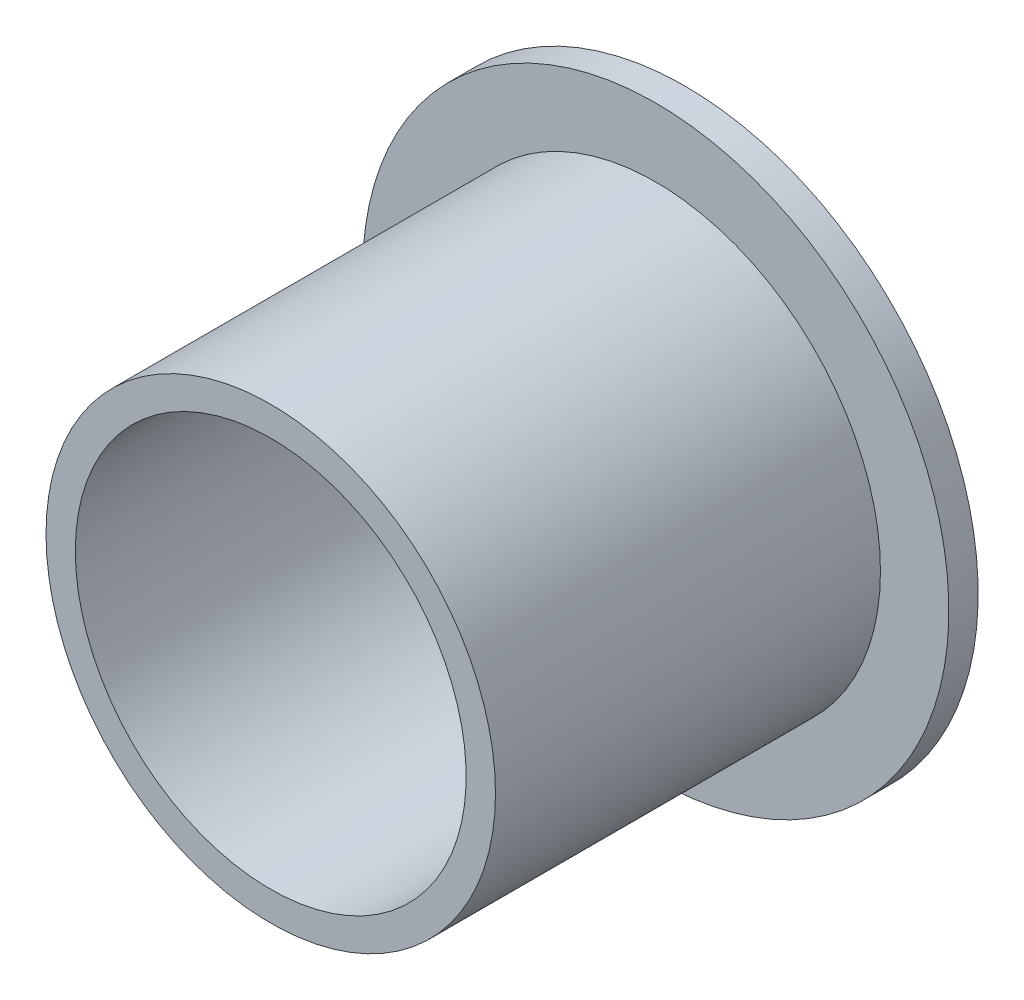
from build123d import *


with BuildPart() as part:
    # Sketch1 → Revolve1 (revolve)
    with BuildSketch(Plane(origin=(0, 0, 0), x_dir=(0, 0, -1), z_dir=(1, 0, 0))):
        Polygon((1.5, 10), (-19.7, 10), (-19.7, 11.5), (0, 11.5), (0, 15), (1.5, 15), align=None)
    revolve(axis=Axis((0, 0, 0), (0, 0, 1)))


solid = part.part
